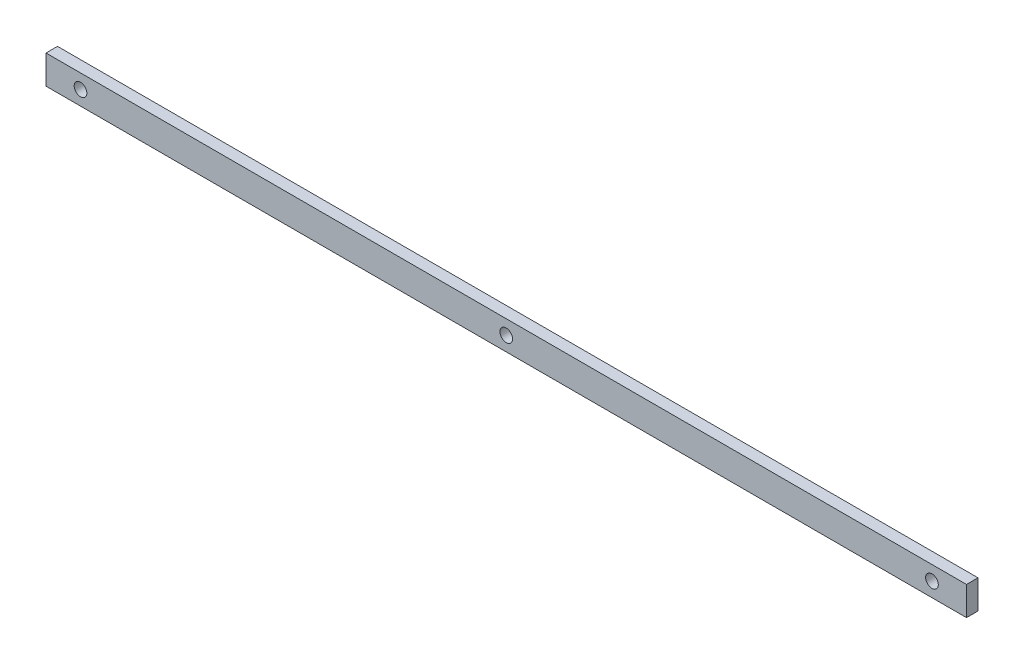
from build123d import *

# Parameters (mm, degrees)
SKETCH1_W           = 800
SKETCH1_H           = 25
BOSS_EXTRUDE1_DEPTH = 10
SKETCH2_R           = 5.5
CUT_EXTRUDE1_DEPTH  = 20


with BuildPart() as part:
    # Sketch1 → Boss-Extrude1 (new body)
    with BuildSketch(Plane.XY):
        Rectangle(SKETCH1_W, SKETCH1_H)
    extrude(amount=BOSS_EXTRUDE1_DEPTH)

    # Sketch2 → Cut-Extrude1 (cut)
    with BuildSketch(Plane.XY):
        with Locations((370, 0)):
            Circle(SKETCH2_R)
        with Locations((-370, 0)):
            Circle(SKETCH2_R)
        Circle(SKETCH2_R)
    extrude(amount=CUT_EXTRUDE1_DEPTH, mode=Mode.SUBTRACT)


solid = part.part
